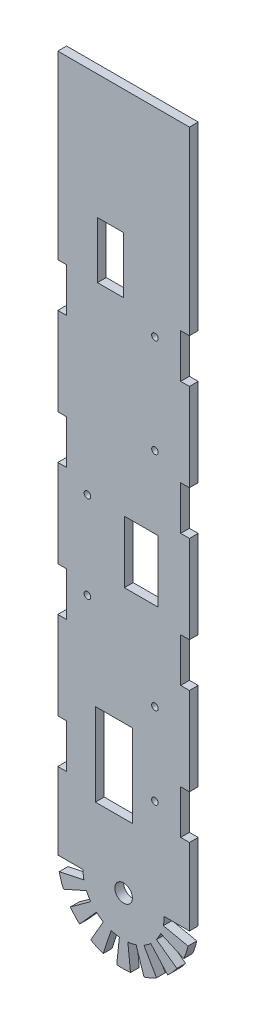
from build123d import *

# Parameters (mm, degrees)
SKETCH1_R           = 1.5
SKETCH1_R_2         = 4.000000004
SKETCH1_W           = 15.264959334
SKETCH1_H           = 28.225795916
SKETCH1_W_2         = 16.875415015
SKETCH1_H_2         = 37.724658957
BOSS_EXTRUDE1_DEPTH = 4


with BuildPart() as part:
    # Sketch1 → Boss-Extrude1 (new body)
    with BuildSketch(Plane.XY):
        with BuildLine():
            Line((-30.000000002, 34.937585276), (-30.000000002, -5e-09))
            Line((-30.000000002, -5e-09), (-18.500000007, -5e-09))
            ThreePointArc((-18.500000007, -5e-09), (-18.398655071, -1.933776576), (-18.09573062, -3.846366286))
            Line((-18.09573062, -3.846366286), (-29.344428024, -6.23735073))
            ThreePointArc((-29.344428024, -6.23735073), (-28.53169549, -9.270509837), (-27.406363731, -12.202099298))
            Line((-27.406363731, -12.202099298), (-16.900590972, -7.524627904))
            ThreePointArc((-16.900590972, -7.524627904), (-16.021469975, -9.250000008), (-14.966814401, -10.874027176))
            Line((-14.966814401, -10.874027176), (-24.270509832, -17.633557574))
            ThreePointArc((-24.270509832, -17.633557574), (-22.294344765, -20.073918196), (-20.073918191, -22.294344769))
            Line((-20.073918191, -22.294344769), (-12.378916221, -13.74817928))
            ThreePointArc((-12.378916221, -13.74817928), (-10.87402717, -14.966814404), (-9.250000002, -16.021469978))
            Line((-9.250000002, -16.021469978), (-14.999999999, -25.980762117))
            ThreePointArc((-14.999999999, -25.980762117), (-12.202099292, -27.406363733), (-9.27050983, -28.531695491))
            Line((-9.27050983, -28.531695491), (-5.716814397, -17.594545559))
            ThreePointArc((-5.716814397, -17.594545559), (-3.846366281, -18.09573062), (-1.933776571, -18.39865507))
            Line((-1.933776571, -18.39865507), (-3.135853898, -29.835656862))
            ThreePointArc((-3.135853898, -29.835656862), (0, -30.000000001), (3.135853897, -29.835656861))
            Line((3.135853897, -29.835656861), (1.93377657, -18.398655069))
            ThreePointArc((1.93377657, -18.398655069), (3.84636628, -18.095730618), (5.716814395, -17.594545555))
            Line((5.716814395, -17.594545555), (9.270509829, -28.531695488))
            ThreePointArc((9.270509829, -28.531695488), (12.202099289, -27.406363728), (14.999999996, -25.980762112))
            Line((14.999999996, -25.980762112), (9.249999999, -16.021469973))
            ThreePointArc((9.249999999, -16.021469973), (10.874027165, -14.966814398), (12.378916215, -13.748179274))
            Line((12.378916215, -13.748179274), (20.073918185, -22.294344763))
            ThreePointArc((20.073918185, -22.294344763), (22.294344757, -20.07391819), (24.270509823, -17.633557568))
            Line((24.270509823, -17.633557568), (14.966814392, -10.87402717))
            ThreePointArc((14.966814392, -10.87402717), (16.021469966, -9.250000002), (16.900590962, -7.5246279))
            Line((16.900590962, -7.5246279), (27.40636372, -12.202099293))
            ThreePointArc((27.40636372, -12.202099293), (28.531695479, -9.270509833), (29.344428012, -6.237350727))
            Line((29.344428012, -6.237350727), (18.095730608, -3.846366284))
            ThreePointArc((18.095730608, -3.846366284), (18.398655059, -1.933776575), (18.499999994, -5e-09))
            Line((18.499999994, -5e-09), (29.999999989, -5e-09))
            Line((29.999999989, -5e-09), (29.999999989, 34.937585276))
            Line((29.999999989, 34.937585276), (25.999999989, 34.935484549))
            Line((25.999999989, 34.935484549), (25.999999989, 54.935484549))
            Line((25.999999989, 54.935484549), (29.999999989, 54.937585276))
            Line((29.999999989, 54.937585276), (29.999999989, 94.937585276))
            Line((29.999999989, 94.937585276), (25.999999989, 94.935484549))
            Line((25.999999989, 94.935484549), (25.999999989, 114.935484549))
            Line((25.999999989, 114.935484549), (29.999999989, 114.937585276))
            Line((29.999999989, 114.937585276), (29.999999989, 154.937585276))
            Line((29.999999989, 154.937585276), (25.999999989, 154.935484549))
            Line((25.999999989, 154.935484549), (25.999999989, 174.935484549))
            Line((25.999999989, 174.935484549), (29.999999989, 174.937585276))
            Line((29.999999989, 174.937585276), (29.999999989, 214.937585276))
            Line((29.999999989, 214.937585276), (25.999999989, 214.935484549))
            Line((25.999999989, 214.935484549), (25.999999989, 234.935484549))
            Line((25.999999989, 234.935484549), (29.999999989, 234.937585276))
            Line((29.999999989, 234.937585276), (29.999999989, 317.280454814))
            Line((29.999999989, 317.280454814), (-30.000000002, 317.280454814))
            Line((-30.000000002, 317.280454814), (-30.000000002, 234.937585276))
            Line((-30.000000002, 234.937585276), (-26.000000002, 234.935484549))
            Line((-26.000000002, 234.935484549), (-26.000000002, 214.935484549))
            Line((-26.000000002, 214.935484549), (-30.000000002, 214.937585276))
            Line((-30.000000002, 214.937585276), (-30.000000002, 174.937585276))
            Line((-30.000000002, 174.937585276), (-26.000000002, 174.935484549))
            Line((-26.000000002, 174.935484549), (-26.000000002, 154.935484549))
            Line((-26.000000002, 154.935484549), (-30.000000002, 154.937585276))
            Line((-30.000000002, 154.937585276), (-30.000000002, 114.937585276))
            Line((-30.000000002, 114.937585276), (-26.000000002, 114.935484549))
            Line((-26.000000002, 114.935484549), (-26.000000002, 94.935484549))
            Line((-26.000000002, 94.935484549), (-30.000000002, 94.937585276))
            Line((-30.000000002, 94.937585276), (-30.000000002, 54.937585276))
            Line((-30.000000002, 54.937585276), (-26.000000002, 54.935484549))
            Line((-26.000000002, 54.935484549), (-26.000000002, 34.935484549))
            Line((-26.000000002, 34.935484549), (-30.000000002, 34.937585276))
        make_face()
        with Locations((14.272904266, 226.626719069)):
            Circle(SKETCH1_R, mode=Mode.SUBTRACT)
        with Locations((-6e-09, -5e-09)):
            Circle(SKETCH1_R_2, mode=Mode.SUBTRACT)
        with Locations((14.272904266, 181.743471482)):
            Circle(SKETCH1_R, mode=Mode.SUBTRACT)
        with Locations((-16.500000002, 148.89892656)):
            Circle(SKETCH1_R, mode=Mode.SUBTRACT)
        with Locations((-16.500000002, 109.235963146)):
            Circle(SKETCH1_R, mode=Mode.SUBTRACT)
        with Locations((14.272904266, 80.661965148)):
            Circle(SKETCH1_R, mode=Mode.SUBTRACT)
        with Locations((14.272904266, 43.392817658)):
            Circle(SKETCH1_R, mode=Mode.SUBTRACT)
        Polygon((-11.924742875, 260.626143035), (0, 260.626143035), (-2e-09, 234.935484549), (-11.924742875, 234.935484549), align=None, mode=Mode.SUBTRACT)
        with Locations((7.963115832, 134.786028602)):
            Rectangle(SKETCH1_W, SKETCH1_H, mode=Mode.SUBTRACT)
        with Locations((-4.43770751, 48.307901023)):
            Rectangle(SKETCH1_W_2, SKETCH1_H_2, mode=Mode.SUBTRACT)
    extrude(amount=BOSS_EXTRUDE1_DEPTH)


solid = part.part
